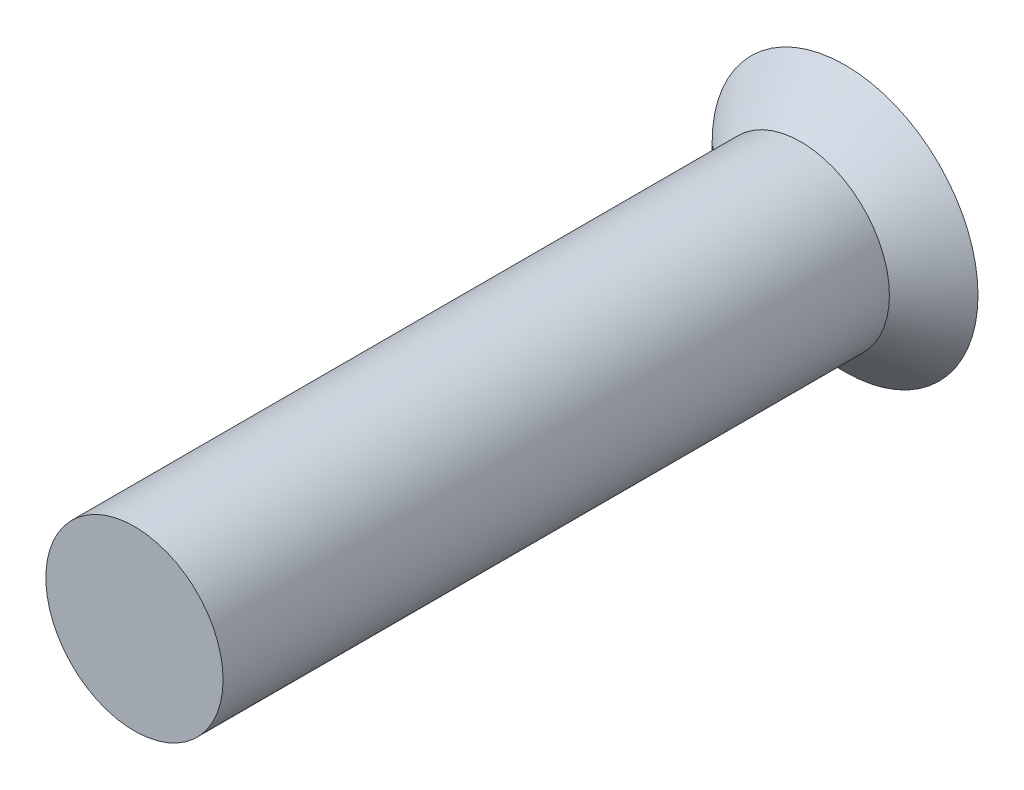
from build123d import *

# Parameters (mm, degrees)
SKETCH1_R           = 0.5
BOSS_EXTRUDE1_DEPTH = 1.88
CUT_EXTRUDE1_DEPTH  = 0.1


with BuildPart() as part:
    # Sketch1 → Boss-Extrude1 (new body, symmetric)
    with BuildSketch(Plane.XY):
        Circle(SKETCH1_R)
    extrude(amount=BOSS_EXTRUDE1_DEPTH, both=True)

    # Sketch2 → Revolve1 (revolve)
    with BuildSketch(Plane(origin=(0, 0, 0), x_dir=(0, 0, -1), z_dir=(1, 0, 0))):
        Polygon((1.88, 0.5), (2.13, 0.75), (2.13, 0), (1.88, 0), align=None)
    revolve(axis=Axis((0, 0, 2.0805), (0, 0, -1)))

    # Sketch3 → Cut-Extrude1 (cut)
    with BuildSketch(Plane(origin=(0, 0, -2.13), x_dir=(-1, 0, 0), z_dir=(0, 0, -1))):
        Polygon((-0.1, 0.6), (-0.1, 0.1), (-0.6, 0.1), (-0.6, -0.1), (-0.1, -0.1), (-0.1, -0.6), (0.1, -0.6), (0.1, -0.1), (0.6, -0.1), (0.6, 0.1), (0.1, 0.1), (0.1, 0.6), align=None)
    extrude(amount=-CUT_EXTRUDE1_DEPTH, mode=Mode.SUBTRACT)


solid = part.part
